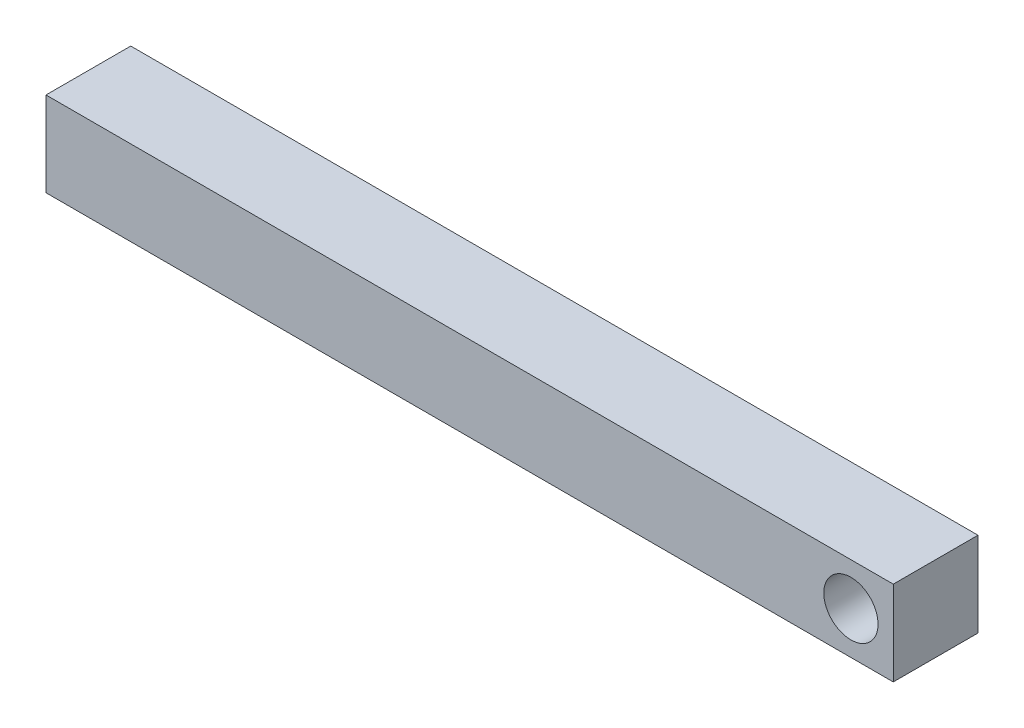
from build123d import *

# Parameters (mm, degrees)
SKETCH1_W           = 250
SKETCH1_H           = 25
BOSS_EXTRUDE1_DEPTH = 25
SKETCH2_R           = 8
CUT_EXTRUDE1_DEPTH  = 26


with BuildPart() as part:
    # Sketch1 → Boss-Extrude1 (new body)
    with BuildSketch(Plane(origin=(0, 0, 0), x_dir=(1, 0, 0), z_dir=(0, 1, 0))):
        with Locations((125, 12.5)):
            Rectangle(SKETCH1_W, SKETCH1_H)
    extrude(amount=BOSS_EXTRUDE1_DEPTH)

    # Sketch2 → Cut-Extrude1 (cut, through all)
    with BuildSketch(Plane.XY):
        with Locations((237.5, 12.5)):
            Circle(SKETCH2_R)
    extrude(amount=-CUT_EXTRUDE1_DEPTH, mode=Mode.SUBTRACT)


solid = part.part
